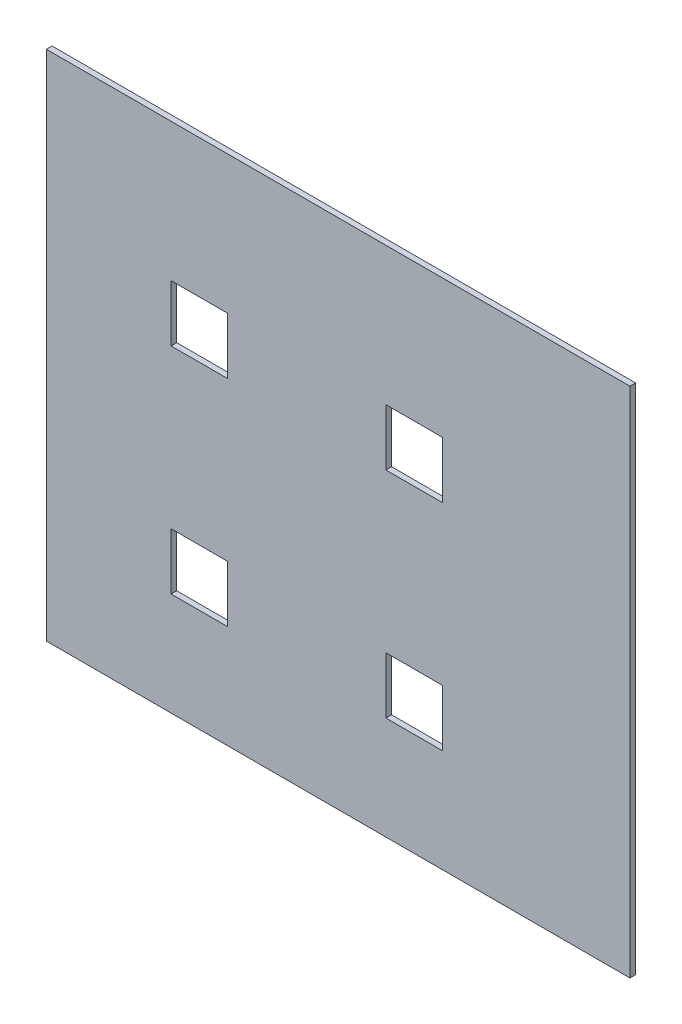
from build123d import *

# Parameters (mm, degrees)
ESQUISSE1_W        = 103.213442027
ESQUISSE1_H        = 90.655152503
ESQUISSE1_W_2      = 10
ESQUISSE1_H_2      = 10
BOSS_EXTRU_1_DEPTH = 1


with BuildPart() as part:
    # Esquisse1 → Boss.-Extru.1 (new body)
    with BuildSketch(Plane.XY):
        with Locations((29.557680179, 27.090374546)):
            Rectangle(ESQUISSE1_W, ESQUISSE1_H)
        with Locations((5, 5)):
            Rectangle(ESQUISSE1_W_2, ESQUISSE1_H_2, mode=Mode.SUBTRACT)
        with Locations((43, 5)):
            Rectangle(ESQUISSE1_W_2, ESQUISSE1_H_2, mode=Mode.SUBTRACT)
        with Locations((43, 43)):
            Rectangle(ESQUISSE1_W_2, ESQUISSE1_H_2, mode=Mode.SUBTRACT)
        with Locations((5, 43)):
            Rectangle(ESQUISSE1_W_2, ESQUISSE1_H_2, mode=Mode.SUBTRACT)
    extrude(amount=BOSS_EXTRU_1_DEPTH)


solid = part.part
